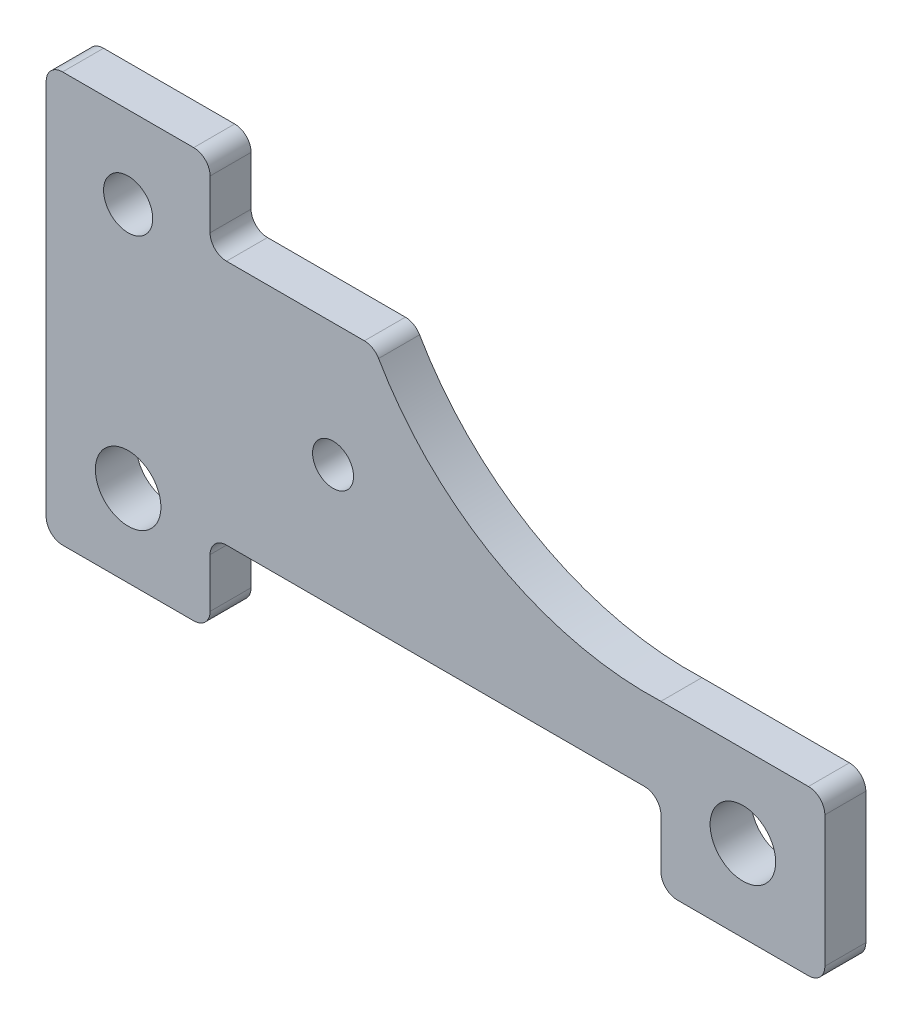
from build123d import *

# Parameters (mm, degrees)
SKETCH1_R           = 30
SKETCH1_R_2         = 40
SKETCH1_R_3         = 25
BOSS_EXTRUDE1_DEPTH = 25


with BuildPart() as part:
    # Sketch1 → Boss-Extrude1 (new body, symmetric)
    with BuildSketch(Plane.XY):
        with BuildLine():
            Line((200, 480), (200, 420))
            ThreePointArc((200, 420), (205.857864376, 405.857864376), (220, 400))
            Line((220, 400), (388.241879306, 400))
            ThreePointArc((388.241879306, 400), (398.249452654, 397.316133393), (405.571126809, 389.984847569))
            ThreePointArc((405.571126809, 389.984847569), (551.290675458, 246.959096298), (750, 200))
            Line((750, 200), (930, 200))
            ThreePointArc((930, 200), (944.142135624, 194.142135624), (950, 180))
            Line((950, 180), (950, 20))
            ThreePointArc((950, 20), (944.142135624, 5.857864376), (930, 0))
            Line((930, 0), (770, 0))
            ThreePointArc((770, 0), (755.857864376, 5.857864376), (750, 20))
            Line((750, 20), (750, 80))
            ThreePointArc((750, 80), (744.142135624, 94.142135624), (730, 100))
            Line((730, 100), (220, 100))
            ThreePointArc((220, 100), (205.857864376, 94.142135624), (200, 80))
            Line((200, 80), (200, 20))
            ThreePointArc((200, 20), (194.142135624, 5.857864376), (180, 0))
            Line((180, 0), (20, 0))
            ThreePointArc((20, 0), (5.857864376, 5.857864376), (0, 20))
            Line((0, 20), (0, 480))
            ThreePointArc((0, 480), (5.857864376, 494.142135624), (20, 500))
            Line((20, 500), (180, 500))
            ThreePointArc((180, 500), (194.142135624, 494.142135624), (200, 480))
        make_face()
        with Locations((100, 400)):
            Circle(SKETCH1_R, mode=Mode.SUBTRACT)
        with Locations((100, 100)):
            Circle(SKETCH1_R_2, mode=Mode.SUBTRACT)
        with Locations((350, 250)):
            Circle(SKETCH1_R_3, mode=Mode.SUBTRACT)
        with Locations((850, 100)):
            Circle(SKETCH1_R_2, mode=Mode.SUBTRACT)
    extrude(amount=BOSS_EXTRUDE1_DEPTH, both=True)


solid = part.part
